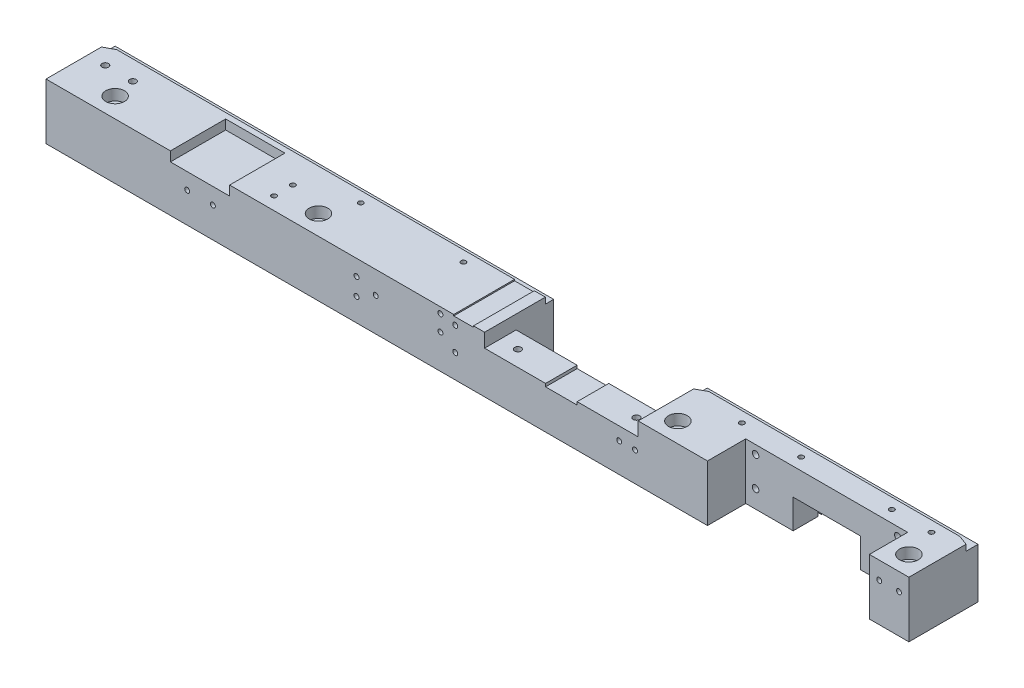
from build123d import *

# Parameters (mm, degrees)
BOSS_EXTRUDE1_DEPTH   = 35
SKETCH2_W             = 30
SKETCH2_H             = 28
CUT_EXTRUDE1_DEPTH    = 4.85
SKETCH3_W             = 77.8
SKETCH3_H             = 19
CUT_EXTRUDE2_DEPTH    = 22.35
SKETCH4_W             = 82
SKETCH4_H             = 19.37
CUT_EXTRUDE3_DEPTH    = 29.35
CUT_EXTRUDE5_DEPTH    = 3.08
SKETCH7_W             = 68
SKETCH7_H             = 1.6
CUT_EXTRUDE6_DEPTH    = 26.27
SKETCH8_R             = 2.75
CUT_EXTRUDE7_DEPTH    = 29.35
SKETCH9_R             = 4.75
CUT_EXTRUDE8_DEPTH    = 5.5
M4_TAPPED_HOLE1_D     = 3.3
M4_TAPPED_HOLE1_DEPTH = 8
M4_TAPPED_HOLE1_TIP   = 0.991420021
M4_TAPPED_HOLE2_D     = 3.3
M4_TAPPED_HOLE2_DEPTH = 8
M4_TAPPED_HOLE2_TIP   = 0.991420021
M3_TAPPED_HOLE1_D     = 2.5
M3_TAPPED_HOLE1_DEPTH = 6
M3_TAPPED_HOLE1_TIP   = 0.751075774
M3_TAPPED_HOLE2_D     = 2.5
M3_TAPPED_HOLE2_DEPTH = 6
M3_TAPPED_HOLE2_TIP   = 0.751075774
M3_TAPPED_HOLE3_D     = 2.5
M3_TAPPED_HOLE3_DEPTH = 6
M3_TAPPED_HOLE3_TIP   = 0.751075774
M4_TAPPED_HOLE3_D     = 3.3
M4_TAPPED_HOLE3_DEPTH = 8
M4_TAPPED_HOLE3_TIP   = 0.991420021
SKETCH22_W            = 10
SKETCH22_H            = 30.806567365
CUT_EXTRUDE9_DEPTH    = 0.65


with BuildPart() as part:
    # Sketch1 → Boss-Extrude1 (new body)
    with BuildSketch(Plane.XY):
        Polygon((267.075702076, 27.942429792), (311.075702076, 27.942429792), (311.075702076, 56.292429792), (173.975702076, 56.292429792), (173.975702076, 49.292429792), (143.075702076, 49.292429792), (143.075702076, 47.785708056), (127.075702076, 47.785708056), (127.075702076, 49.292429792), (96.175702076, 49.292429792), (96.175702076, 56.292429792), (-125.924297924, 56.292429792), (-125.924297924, 27.942429792), (233.075702076, 27.942429792), (233.075702076, 42.742429792), (267.075702076, 42.742429792), align=None)
    extrude(amount=BOSS_EXTRUDE1_DEPTH)

    # Sketch2 → Cut-Extrude1 (cut)
    with BuildSketch(Plane(origin=(0, 56.292429792, 0), x_dir=(1, 0, 0), z_dir=(0, 1, 0))):
        with Locations((-47.924297924, -21)):
            Rectangle(SKETCH2_W, SKETCH2_H)
    extrude(amount=-CUT_EXTRUDE1_DEPTH, mode=Mode.SUBTRACT)

    # Sketch3 → Cut-Extrude2 (cut, through all)
    with BuildSketch(Plane(origin=(0, 49.292429792, 0), x_dir=(1, 0, 0), z_dir=(0, 1, 0))):
        with Locations((135.075702076, -9.5)):
            Rectangle(SKETCH3_W, SKETCH3_H)
    extrude(amount=-CUT_EXTRUDE2_DEPTH, mode=Mode.SUBTRACT)

    # Sketch4 → Cut-Extrude3 (cut, through all)
    with BuildSketch(Plane(origin=(0, 56.292429792, 0), x_dir=(1, 0, 0), z_dir=(0, 1, 0))):
        with Locations((250.075702076, -25.315)):
            Rectangle(SKETCH4_W, SKETCH4_H)
    extrude(amount=-CUT_EXTRUDE3_DEPTH, mode=Mode.SUBTRACT)

    # Sketch5 → Cut-Extrude5 (cut)
    with BuildSketch(Plane(origin=(0, 56.292429792, 0), x_dir=(1, 0, 0), z_dir=(0, 1, 0))):
        Polygon((-125.924297924, -6.922171551), (-120.924297924, -4.193432635), (96.175702076, -4.193432635), (173.975702076, -4.193432635), (173.975702076, -6.922171551), (178.975702076, -4.193432635), (306.075702076, -4.193432635), (311.075702076, -6.043688669), (311.075702076, 0), (-125.924297924, 0), align=None)
    extrude(amount=-CUT_EXTRUDE5_DEPTH, mode=Mode.SUBTRACT)

    # Sketch7 → Cut-Extrude6 (cut, through all)
    with BuildSketch(Plane(origin=(0, 53.212429792, 0), x_dir=(1, 0, 0), z_dir=(0, 1, 0))):
        with Locations((250.075702076, -2.13)):
            Rectangle(SKETCH7_W, SKETCH7_H)
    extrude(amount=-CUT_EXTRUDE6_DEPTH, mode=Mode.SUBTRACT)

    # Sketch8 → Cut-Extrude7 (cut, through all)
    with BuildSketch(Plane(origin=(0, 56.292429792, 0), x_dir=(1, 0, 0), z_dir=(0, 1, 0))):
        with Locations((-100.924297924, -25)):
            Circle(SKETCH8_R)
        with Locations((2.075702076, -25)):
            Circle(SKETCH8_R)
        with Locations((184.075702076, -25)):
            Circle(SKETCH8_R)
        with Locations((301.075702076, -25)):
            Circle(SKETCH8_R)
    extrude(amount=-CUT_EXTRUDE7_DEPTH, mode=Mode.SUBTRACT)

    # Sketch9 → Cut-Extrude8 (cut)
    with BuildSketch(Plane(origin=(0, 56.292429792, 0), x_dir=(1, 0, 0), z_dir=(0, 1, 0))):
        with Locations((-100.924297924, -25)):
            Circle(SKETCH9_R)
        with Locations((2.075702076, -25)):
            Circle(SKETCH9_R)
        with Locations((184.075702076, -25)):
            Circle(SKETCH9_R)
        with Locations((301.075702076, -25)):
            Circle(SKETCH9_R)
    extrude(amount=-CUT_EXTRUDE8_DEPTH, mode=Mode.SUBTRACT)

    # M4 Tapped Hole1
    with Locations(Plane(origin=(0, 56.292429792, 0), x_dir=(1, 0, 0), z_dir=(0, 1, 0))):
        with Locations((-116.924297924, -14), (-102.924297924, -14)):
            Hole(M4_TAPPED_HOLE1_D / 2, depth=M4_TAPPED_HOLE1_DEPTH)
            with Locations((0, 0, -(M4_TAPPED_HOLE1_DEPTH + M4_TAPPED_HOLE1_TIP / 2))):  # 118° drill point
                Cone(0, M4_TAPPED_HOLE1_D / 2, M4_TAPPED_HOLE1_TIP, mode=Mode.SUBTRACT)

    # M4 Tapped Hole2
    with Locations(Plane(origin=(0, 49.292429792, 0), x_dir=(1, 0, 0), z_dir=(0, 1, 0))):
        with Locations((105.075702076, -27), (165.075702076, -27)):
            Hole(M4_TAPPED_HOLE2_D / 2, depth=M4_TAPPED_HOLE2_DEPTH)
            with Locations((0, 0, -(M4_TAPPED_HOLE2_DEPTH + M4_TAPPED_HOLE2_TIP / 2))):  # 118° drill point
                Cone(0, M4_TAPPED_HOLE2_D / 2, M4_TAPPED_HOLE2_TIP, mode=Mode.SUBTRACT)

    # M3 Tapped Hole1
    with Locations(Plane(origin=(0, 56.292429792, 0), x_dir=(1, 0, 0), z_dir=(0, 1, 0))):
        with Locations((-16.924297924, -19), (-16.924297924, -28.5), (8.075702076, -9.6), (60.075702076, -9.6), (201.075702076, -9.6), (231.075702076, -9.6), (277.075702076, -9.6), (297.075702076, -9.6)):
            Hole(M3_TAPPED_HOLE1_D / 2, depth=M3_TAPPED_HOLE1_DEPTH)
            with Locations((0, 0, -(M3_TAPPED_HOLE1_DEPTH + M3_TAPPED_HOLE1_TIP / 2))):  # 118° drill point
                Cone(0, M3_TAPPED_HOLE1_D / 2, M3_TAPPED_HOLE1_TIP, mode=Mode.SUBTRACT)

    # M3 Tapped Hole2
    with Locations(Plane.XY.offset(35)):
        with Locations((-54.424297924, 43.292429792), (-41.424297924, 43.292429792), (31.325702076, 48.307679659), (31.325702076, 39.562572504), (41.075702076, 44.894954915), (81.325702076, 51.942429792), (81.325702076, 39.942429792), (164.375702076, 42.742429792), (172.375702076, 42.742429792), (296.075702076, 47.442429792), (306.075702076, 47.442429792)):
            Hole(M3_TAPPED_HOLE2_D / 2, depth=M3_TAPPED_HOLE2_DEPTH)
            with Locations((0, 0, -(M3_TAPPED_HOLE2_DEPTH + M3_TAPPED_HOLE2_TIP / 2))):  # 118° drill point
                Cone(0, M3_TAPPED_HOLE2_D / 2, M3_TAPPED_HOLE2_TIP, mode=Mode.SUBTRACT)

    # M3 Tapped Hole3
    with Locations(Plane.XY.offset(35)):
        with Locations((73.822463361, 53.212429792), (73.822463361, 45.212429792)):
            Hole(M3_TAPPED_HOLE3_D / 2, depth=M3_TAPPED_HOLE3_DEPTH)
            with Locations((0, 0, -(M3_TAPPED_HOLE3_DEPTH + M3_TAPPED_HOLE3_TIP / 2))):  # 118° drill point
                Cone(0, M3_TAPPED_HOLE3_D / 2, M3_TAPPED_HOLE3_TIP, mode=Mode.SUBTRACT)

    # M4 Tapped Hole3
    with Locations(Plane.XY.offset(15.63)):
        with Locations((214.075702076, 51.942429792), (214.075702076, 36.942429792), (286.075702076, 36.942429792), (286.075702076, 51.942429792)):
            Hole(M4_TAPPED_HOLE3_D / 2, depth=M4_TAPPED_HOLE3_DEPTH)
            with Locations((0, 0, -(M4_TAPPED_HOLE3_DEPTH + M4_TAPPED_HOLE3_TIP / 2))):  # 118° drill point
                Cone(0, M4_TAPPED_HOLE3_D / 2, M4_TAPPED_HOLE3_TIP, mode=Mode.SUBTRACT)

    # Sketch22 → Cut-Extrude9 (cut)
    with BuildSketch(Plane(origin=(0, 56.292429792, 0), x_dir=(1, 0, 0), z_dir=(0, 1, 0))):
        with Locations((85.575702076, -19.596716318)):
            Rectangle(SKETCH22_W, SKETCH22_H)
    extrude(amount=-CUT_EXTRUDE9_DEPTH, mode=Mode.SUBTRACT)


solid = part.part
